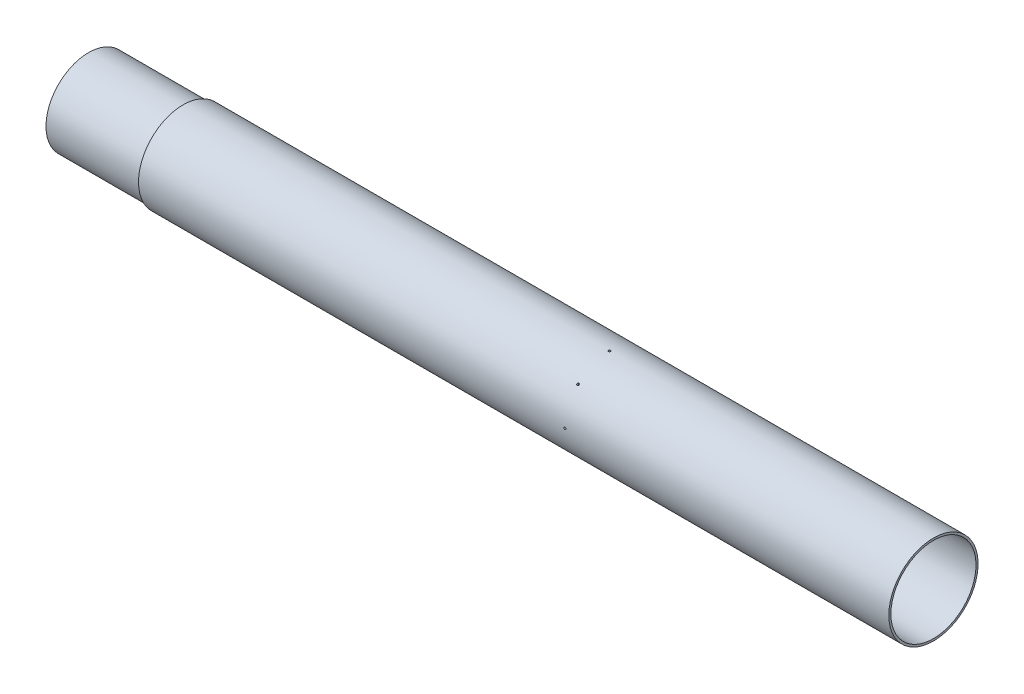
from build123d import *

# Parameters (mm, degrees)
SKETCH2_R          = 1.4224
CUT_EXTRUDE1_DEPTH = 20
CIRPATTERN1_COUNT  = 8


with BuildPart() as part:
    # Sketch1 → Revolve1 (revolve)
    with BuildSketch(Plane.XY):
        Polygon((-1238.910735908, 59.93638), (-2246.556635908, 59.93638), (-2246.556635908, 57.15), (-2373.556635908, 57.15), (-2373.556635908, 54.36362), (-2119.556635908, 54.36362), (-2119.556635908, 57.15), (-1238.910735908, 57.15), align=None)
    revolve(axis=Axis((-2246.556635908, 0, 0), (1, 0, 0)))

    # Sketch2 → Cut-Extrude1 (cut)
    with BuildSketch(Plane(origin=(0, 0, -59.93638), x_dir=(-1, 0, 0), z_dir=(0, 0, -1))):
        with Locations((1673.910735908, 0)):
            Circle(SKETCH2_R)
    cut_extrude1 = extrude(amount=-CUT_EXTRUDE1_DEPTH, mode=Mode.SUBTRACT)

    # CirPattern1: Cut-Extrude1 ×8 about axis
    cirpattern1_axis = Axis((-1238.910735908, 0, 0), (-1, 0, 0))
    for i in range(1, CIRPATTERN1_COUNT):
        add(cut_extrude1.rotate(cirpattern1_axis, i * 360 / CIRPATTERN1_COUNT), mode=Mode.SUBTRACT)


solid = part.part
